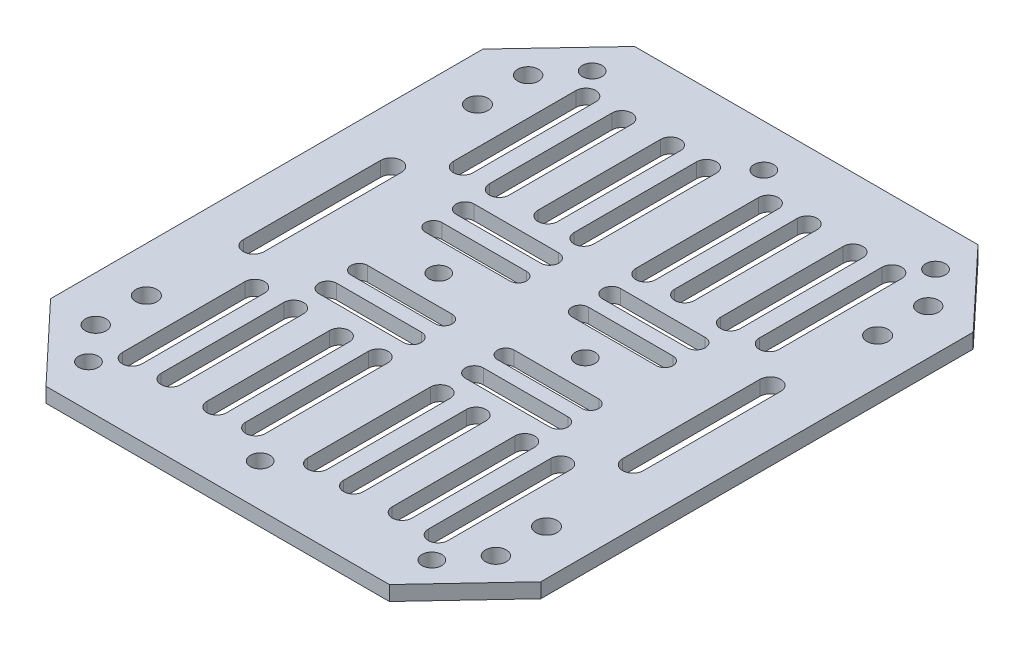
from build123d import *

# Parameters (mm, degrees)
SKETCH1_R           = 2
SKETCH1_R_2         = 2.121489713
SKETCH1_R_3         = 2.167002768
BOSS_EXTRUDE1_DEPTH = 3


with BuildPart() as part:
    # Sketch1 → Boss-Extrude1 (new body)
    with BuildSketch(Plane(origin=(0, 0, 0), x_dir=(1, 0, 0), z_dir=(0, 1, 0))):
        Polygon((-19.834673132, -51.367200065), (-89.834673132, -51.367200065), (-104.834673132, -35.440900491), (-104.834673132, 52.70650036), (-89.834673132, 68.632799935), (-19.834673132, 68.632799935), (-4.887663235, 52.70650036), (-4.887663235, -35.440900491), align=None)
        with Locations((-89.834673132, -42.706946028)):
            Circle(SKETCH1_R, mode=Mode.SUBTRACT)
        with Locations((-54.834673132, -42.706946028)):
            Circle(SKETCH1_R, mode=Mode.SUBTRACT)
        with Locations((-89.834673132, 59.972545897)):
            Circle(SKETCH1_R, mode=Mode.SUBTRACT)
        with Locations((-54.834673132, 59.972545897)):
            Circle(SKETCH1_R, mode=Mode.SUBTRACT)
        with Locations((-19.834673132, 59.972545897)):
            Circle(SKETCH1_R, mode=Mode.SUBTRACT)
        with Locations((-19.834673132, -42.706946028)):
            Circle(SKETCH1_R, mode=Mode.SUBTRACT)
        with Locations((-95.619101604, 52.70650036)):
            Circle(SKETCH1_R_2, mode=Mode.SUBTRACT)
        with Locations((-95.619101604, 42.380285931)):
            Circle(SKETCH1_R_3, mode=Mode.SUBTRACT)
        with Locations((-39.897791716, 8.632799935)):
            Circle(SKETCH1_R, mode=Mode.SUBTRACT)
        with Locations((-69.771554548, 8.632799935)):
            Circle(SKETCH1_R, mode=Mode.SUBTRACT)
        with Locations((-95.619101604, -25.114686061)):
            Circle(SKETCH1_R_3, mode=Mode.SUBTRACT)
        with Locations((-95.619101604, -35.440900491)):
            Circle(SKETCH1_R_2, mode=Mode.SUBTRACT)
        with Locations((-14.05024466, -35.440900491)):
            Circle(SKETCH1_R_2, mode=Mode.SUBTRACT)
        with Locations((-14.05024466, -25.114686061)):
            Circle(SKETCH1_R_3, mode=Mode.SUBTRACT)
        with Locations((-14.05024466, 42.380285931)):
            Circle(SKETCH1_R_3, mode=Mode.SUBTRACT)
        with Locations((-14.05024466, 52.70650036)):
            Circle(SKETCH1_R_2, mode=Mode.SUBTRACT)
        with BuildLine():
            Line((-91.376122178, 22.632799935), (-91.376122178, -5.367200065))
            ThreePointArc((-91.376122178, -5.367200065), (-93.497611891, -7.488689778), (-95.619101604, -5.367200065))
            Line((-95.619101604, -5.367200065), (-95.619101604, 22.632799935))
            ThreePointArc((-95.619101604, 22.632799935), (-93.497611891, 24.754289647), (-91.376122178, 22.632799935))
        make_face(mode=Mode.SUBTRACT)
        with BuildLine():
            Line((-18.293224086, 22.632799935), (-18.293224086, -5.367200065))
            ThreePointArc((-18.293224086, -5.367200065), (-16.171734373, -7.488689778), (-14.05024466, -5.367200065))
            Line((-14.05024466, -5.367200065), (-14.05024466, 22.632799935))
            ThreePointArc((-14.05024466, 22.632799935), (-16.171734373, 24.754289647), (-18.293224086, 22.632799935))
        make_face(mode=Mode.SUBTRACT)
        with BuildLine():
            Line((-80.409546658, -37.330748482), (-80.409546658, -12.323750115))
            ThreePointArc((-80.409546658, -12.323750115), (-78.397489318, -10.311692775), (-76.385431978, -12.323750115))
            Line((-76.385431978, -12.323750115), (-76.385431978, -37.330748482))
            ThreePointArc((-76.385431978, -37.330748482), (-78.397489318, -39.342805822), (-80.409546658, -37.330748482))
        make_face(mode=Mode.SUBTRACT)
        with BuildLine():
            Line((-88.038438317, -37.618185245), (-88.038438317, -12.611186878))
            ThreePointArc((-88.038438317, -12.611186878), (-86.026380977, -10.599129538), (-84.014323637, -12.611186878))
            Line((-84.014323637, -12.611186878), (-84.014323637, -37.618185245))
            ThreePointArc((-84.014323637, -37.618185245), (-86.026380977, -39.630242585), (-88.038438317, -37.618185245))
        make_face(mode=Mode.SUBTRACT)
        with BuildLine():
            Line((-63.157677118, -37.330748482), (-63.157677118, -12.323750115))
            ThreePointArc((-63.157677118, -12.323750115), (-61.145619778, -10.311692775), (-59.133562438, -12.323750115))
            Line((-59.133562438, -12.323750115), (-59.133562438, -37.330748482))
            ThreePointArc((-59.133562438, -37.330748482), (-61.145619778, -39.342805822), (-63.157677118, -37.330748482))
        make_face(mode=Mode.SUBTRACT)
        with BuildLine():
            Line((-70.786568777, -37.618185245), (-70.786568777, -12.611186878))
            ThreePointArc((-70.786568777, -12.611186878), (-68.774511437, -10.599129538), (-66.762454097, -12.611186878))
            Line((-66.762454097, -12.611186878), (-66.762454097, -37.618185245))
            ThreePointArc((-66.762454097, -37.618185245), (-68.774511437, -39.630242585), (-70.786568777, -37.618185245))
        make_face(mode=Mode.SUBTRACT)
        with BuildLine():
            Line((-61.145619778, -0.641040531), (-78.397489318, -0.641040531))
            ThreePointArc((-78.397489318, -0.641040531), (-80.098193808, 1.059663959), (-78.397489318, 2.76036845))
            Line((-78.397489318, 2.76036845), (-61.145619778, 2.76036845))
            ThreePointArc((-61.145619778, 2.76036845), (-59.444915288, 1.059663959), (-61.145619778, -0.641040531))
        make_face(mode=Mode.SUBTRACT)
        with BuildLine():
            Line((-61.145619778, -7.197755846), (-78.397489318, -7.197755846))
            ThreePointArc((-78.397489318, -7.197755846), (-80.228045098, -5.367200065), (-78.397489318, -3.536644285))
            Line((-78.397489318, -3.536644285), (-61.145619778, -3.536644285))
            ThreePointArc((-61.145619778, -3.536644285), (-59.315063998, -5.367200065), (-61.145619778, -7.197755846))
        make_face(mode=Mode.SUBTRACT)
        with BuildLine():
            Line((-80.409546658, 54.596348351), (-80.409546658, 29.589349984))
            ThreePointArc((-80.409546658, 29.589349984), (-78.397489318, 27.577292644), (-76.385431978, 29.589349984))
            Line((-76.385431978, 29.589349984), (-76.385431978, 54.596348351))
            ThreePointArc((-76.385431978, 54.596348351), (-78.397489318, 56.608405691), (-80.409546658, 54.596348351))
        make_face(mode=Mode.SUBTRACT)
        with BuildLine():
            Line((-88.038438317, 54.883785114), (-88.038438317, 29.876786747))
            ThreePointArc((-88.038438317, 29.876786747), (-86.026380977, 27.864729407), (-84.014323637, 29.876786747))
            Line((-84.014323637, 29.876786747), (-84.014323637, 54.883785114))
            ThreePointArc((-84.014323637, 54.883785114), (-86.026380977, 56.895842454), (-88.038438317, 54.883785114))
        make_face(mode=Mode.SUBTRACT)
        with BuildLine():
            Line((-63.157677118, 54.596348351), (-63.157677118, 29.589349984))
            ThreePointArc((-63.157677118, 29.589349984), (-61.145619778, 27.577292644), (-59.133562438, 29.589349984))
            Line((-59.133562438, 29.589349984), (-59.133562438, 54.596348351))
            ThreePointArc((-59.133562438, 54.596348351), (-61.145619778, 56.608405691), (-63.157677118, 54.596348351))
        make_face(mode=Mode.SUBTRACT)
        with BuildLine():
            Line((-70.786568777, 54.883785114), (-70.786568777, 29.876786747))
            ThreePointArc((-70.786568777, 29.876786747), (-68.774511437, 27.864729407), (-66.762454097, 29.876786747))
            Line((-66.762454097, 29.876786747), (-66.762454097, 54.883785114))
            ThreePointArc((-66.762454097, 54.883785114), (-68.774511437, 56.895842454), (-70.786568777, 54.883785114))
        make_face(mode=Mode.SUBTRACT)
        with BuildLine():
            Line((-61.145619778, 17.9066404), (-78.397489318, 17.9066404))
            ThreePointArc((-78.397489318, 17.9066404), (-80.098193808, 16.20593591), (-78.397489318, 14.50523142))
            Line((-78.397489318, 14.50523142), (-61.145619778, 14.50523142))
            ThreePointArc((-61.145619778, 14.50523142), (-59.444915288, 16.20593591), (-61.145619778, 17.9066404))
        make_face(mode=Mode.SUBTRACT)
        with BuildLine():
            Line((-61.145619778, 24.463355715), (-78.397489318, 24.463355715))
            ThreePointArc((-78.397489318, 24.463355715), (-80.228045098, 22.632799935), (-78.397489318, 20.802244154))
            Line((-78.397489318, 20.802244154), (-61.145619778, 20.802244154))
            ThreePointArc((-61.145619778, 20.802244154), (-59.315063998, 22.632799935), (-61.145619778, 24.463355715))
        make_face(mode=Mode.SUBTRACT)
        with BuildLine():
            Line((-29.259799606, -37.330748482), (-29.259799606, -12.323750115))
            ThreePointArc((-29.259799606, -12.323750115), (-31.271856946, -10.311692775), (-33.283914286, -12.323750115))
            Line((-33.283914286, -12.323750115), (-33.283914286, -37.330748482))
            ThreePointArc((-33.283914286, -37.330748482), (-31.271856946, -39.342805822), (-29.259799606, -37.330748482))
        make_face(mode=Mode.SUBTRACT)
        with BuildLine():
            Line((-21.630907947, -37.618185245), (-21.630907947, -12.611186878))
            ThreePointArc((-21.630907947, -12.611186878), (-23.642965287, -10.599129538), (-25.655022627, -12.611186878))
            Line((-25.655022627, -12.611186878), (-25.655022627, -37.618185245))
            ThreePointArc((-25.655022627, -37.618185245), (-23.642965287, -39.630242585), (-21.630907947, -37.618185245))
        make_face(mode=Mode.SUBTRACT)
        with BuildLine():
            Line((-46.511669146, -37.330748482), (-46.511669146, -12.323750115))
            ThreePointArc((-46.511669146, -12.323750115), (-48.523726486, -10.311692775), (-50.535783826, -12.323750115))
            Line((-50.535783826, -12.323750115), (-50.535783826, -37.330748482))
            ThreePointArc((-50.535783826, -37.330748482), (-48.523726486, -39.342805822), (-46.511669146, -37.330748482))
        make_face(mode=Mode.SUBTRACT)
        with BuildLine():
            Line((-38.882777487, -37.618185245), (-38.882777487, -12.611186878))
            ThreePointArc((-38.882777487, -12.611186878), (-40.894834827, -10.599129538), (-42.906892167, -12.611186878))
            Line((-42.906892167, -12.611186878), (-42.906892167, -37.618185245))
            ThreePointArc((-42.906892167, -37.618185245), (-40.894834827, -39.630242585), (-38.882777487, -37.618185245))
        make_face(mode=Mode.SUBTRACT)
        with BuildLine():
            Line((-48.523726486, -0.641040531), (-31.271856946, -0.641040531))
            ThreePointArc((-31.271856946, -0.641040531), (-29.571152456, 1.059663959), (-31.271856946, 2.76036845))
            Line((-31.271856946, 2.76036845), (-48.523726486, 2.76036845))
            ThreePointArc((-48.523726486, 2.76036845), (-50.224430976, 1.059663959), (-48.523726486, -0.641040531))
        make_face(mode=Mode.SUBTRACT)
        with BuildLine():
            Line((-48.523726486, -7.197755846), (-31.271856946, -7.197755846))
            ThreePointArc((-31.271856946, -7.197755846), (-29.441301166, -5.367200065), (-31.271856946, -3.536644285))
            Line((-31.271856946, -3.536644285), (-48.523726486, -3.536644285))
            ThreePointArc((-48.523726486, -3.536644285), (-50.354282266, -5.367200065), (-48.523726486, -7.197755846))
        make_face(mode=Mode.SUBTRACT)
        with BuildLine():
            Line((-29.259799606, 54.596348351), (-29.259799606, 29.589349984))
            ThreePointArc((-29.259799606, 29.589349984), (-31.271856946, 27.577292644), (-33.283914286, 29.589349984))
            Line((-33.283914286, 29.589349984), (-33.283914286, 54.596348351))
            ThreePointArc((-33.283914286, 54.596348351), (-31.271856946, 56.608405691), (-29.259799606, 54.596348351))
        make_face(mode=Mode.SUBTRACT)
        with BuildLine():
            Line((-21.630907947, 54.883785114), (-21.630907947, 29.876786747))
            ThreePointArc((-21.630907947, 29.876786747), (-23.642965287, 27.864729407), (-25.655022627, 29.876786747))
            Line((-25.655022627, 29.876786747), (-25.655022627, 54.883785114))
            ThreePointArc((-25.655022627, 54.883785114), (-23.642965287, 56.895842454), (-21.630907947, 54.883785114))
        make_face(mode=Mode.SUBTRACT)
        with BuildLine():
            Line((-46.511669146, 54.596348351), (-46.511669146, 29.589349984))
            ThreePointArc((-46.511669146, 29.589349984), (-48.523726486, 27.577292644), (-50.535783826, 29.589349984))
            Line((-50.535783826, 29.589349984), (-50.535783826, 54.596348351))
            ThreePointArc((-50.535783826, 54.596348351), (-48.523726486, 56.608405691), (-46.511669146, 54.596348351))
        make_face(mode=Mode.SUBTRACT)
        with BuildLine():
            Line((-38.882777487, 54.883785114), (-38.882777487, 29.876786747))
            ThreePointArc((-38.882777487, 29.876786747), (-40.894834827, 27.864729407), (-42.906892167, 29.876786747))
            Line((-42.906892167, 29.876786747), (-42.906892167, 54.883785114))
            ThreePointArc((-42.906892167, 54.883785114), (-40.894834827, 56.895842454), (-38.882777487, 54.883785114))
        make_face(mode=Mode.SUBTRACT)
        with BuildLine():
            Line((-48.523726486, 17.9066404), (-31.271856946, 17.9066404))
            ThreePointArc((-31.271856946, 17.9066404), (-29.571152456, 16.20593591), (-31.271856946, 14.50523142))
            Line((-31.271856946, 14.50523142), (-48.523726486, 14.50523142))
            ThreePointArc((-48.523726486, 14.50523142), (-50.224430976, 16.20593591), (-48.523726486, 17.9066404))
        make_face(mode=Mode.SUBTRACT)
        with BuildLine():
            Line((-48.523726486, 24.463355715), (-31.271856946, 24.463355715))
            ThreePointArc((-31.271856946, 24.463355715), (-29.441301166, 22.632799935), (-31.271856946, 20.802244154))
            Line((-31.271856946, 20.802244154), (-48.523726486, 20.802244154))
            ThreePointArc((-48.523726486, 20.802244154), (-50.354282266, 22.632799935), (-48.523726486, 24.463355715))
        make_face(mode=Mode.SUBTRACT)
    extrude(amount=BOSS_EXTRUDE1_DEPTH)


solid = part.part
